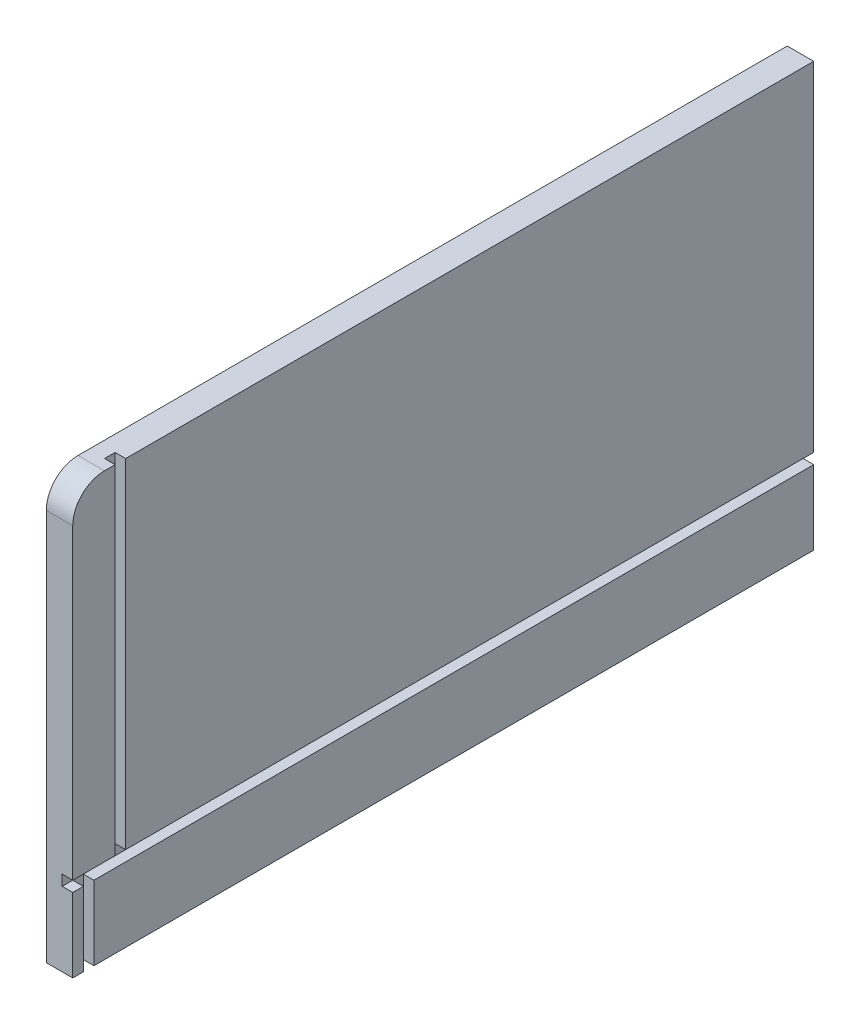
from build123d import *

# Parameters (mm, degrees)
BOSS_EXTRUDE1_DEPTH = 15.875
SKETCH2_W           = 6.35
SKETCH2_H           = 6.35
CUT_EXTRUDE1_DEPTH  = 445.5
CUT_EXTRUDE3_REACH  = 256
SKETCH3_W           = 6.35
SKETCH3_H           = 6.35
CUT_EXTRUDE4_REACH  = 256
SKETCH4_W           = 6.35
SKETCH4_H           = 6.35


with BuildPart() as part:
    # Sketch1 → Boss-Extrude1 (new body)
    with BuildSketch(Plane(origin=(0, 0, 0), x_dir=(0, 0, -1), z_dir=(1, 0, 0))):
        with BuildLine():
            Line((0, 0), (444.5, 0))
            Line((444.5, 0), (444.5, 254))
            Line((444.5, 254), (19.05, 254))
            ThreePointArc((19.05, 254), (5.579615818, 248.420384182), (0, 234.95))
            Line((0, 234.95), (0, 0))
        make_face()
    extrude(amount=BOSS_EXTRUDE1_DEPTH)

    # Sketch2 → Cut-Extrude1 (cut, through all)
    with BuildSketch(Plane(origin=(0, 0, -444.5), x_dir=(-1, 0, 0), z_dir=(0, 0, -1))):
        with Locations((-12.7, 47.625)):
            Rectangle(SKETCH2_W, SKETCH2_H)
    extrude(amount=-CUT_EXTRUDE1_DEPTH, mode=Mode.SUBTRACT)

    # Sketch3 → Cut-Extrude3 (cut, up to next)
    with BuildSketch(Plane.XZ, mode=Mode.PRIVATE) as cut_extrude3_sk1:
        with Locations((12.7, -9.525)):
            Rectangle(SKETCH3_W, SKETCH3_H)
    cut_extrude3_tool1 = extrude(cut_extrude3_sk1.sketch, amount=-CUT_EXTRUDE3_REACH, mode=Mode.PRIVATE) & part.part
    add(cut_extrude3_tool1.solids().sort_by_distance((12.7, 0, -9.525))[0], mode=Mode.SUBTRACT)

    # Sketch4 → Cut-Extrude4 (cut, up to next)
    with BuildSketch(Plane(origin=(0, 254, 0), x_dir=(1, 0, 0), z_dir=(0, 1, 0)), mode=Mode.PRIVATE) as cut_extrude4_sk1:
        with Locations((12.7, 28.575)):
            Rectangle(SKETCH4_W, SKETCH4_H)
    cut_extrude4_tool1 = extrude(cut_extrude4_sk1.sketch, amount=-CUT_EXTRUDE4_REACH, mode=Mode.PRIVATE) & part.part
    add(cut_extrude4_tool1.solids().sort_by_distance((12.7, 254, -28.575))[0], mode=Mode.SUBTRACT)


solid = part.part
